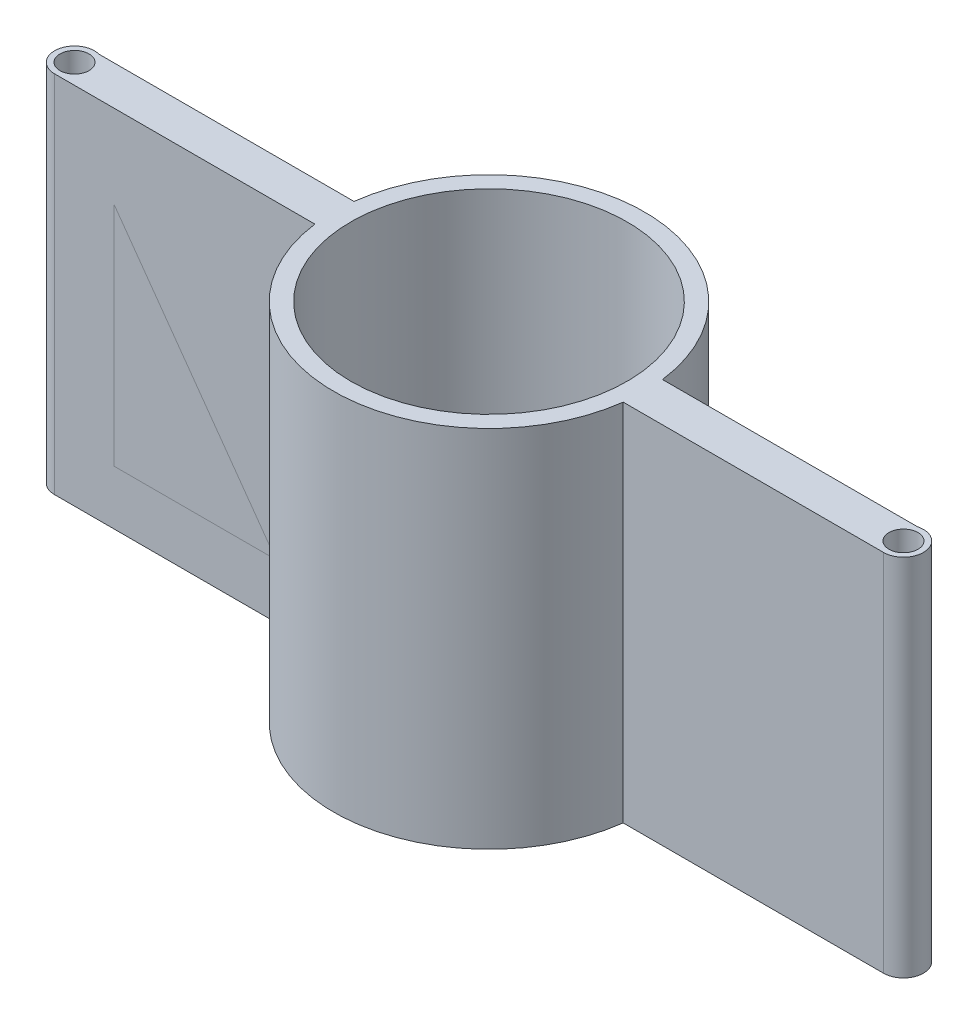
from build123d import *

# Parameters (mm, degrees)
SKETCH1_R           = 25.4
SKETCH1_R_2         = 2.669147435
BOSS_EXTRUDE1_DEPTH = 67
SKETCH4_W           = 36.879658646
SKETCH4_H           = 47
BOSS_EXTRUDE2_DEPTH = 7.209
SKETCH5_W           = 36.879658646
SKETCH5_H           = 47
BOSS_EXTRUDE3_DEPTH = 7.209


with BuildPart() as part:
    # Sketch1 → Boss-Extrude1 (new body)
    with BuildSketch(Plane(origin=(0, 0, 0), x_dir=(1, 0, 0), z_dir=(0, 1, 0))):
        with BuildLine():
            ThreePointArc((76.2, -3.669147435), (79.83668007, 0.487032823), (75.234553617, 3.539852565))
            Line((75.234553617, 3.539852565), (28.354894971, 3.539852565))
            ThreePointArc((28.354894971, 3.539852565), (0, 28.575), (-28.354894971, 3.539852565))
            Line((-28.354894971, 3.539852565), (-75.234553617, 3.539852565))
            ThreePointArc((-75.234553617, 3.539852565), (-79.83668007, 0.487032823), (-76.2, -3.669147435))
            Line((-76.2, -3.669147435), (-28.338454123, -3.669147435))
            ThreePointArc((-28.338454123, -3.669147435), (0, -28.575), (28.338454123, -3.669147435))
            Line((28.338454123, -3.669147435), (76.2, -3.669147435))
        make_face()
        Circle(SKETCH1_R, mode=Mode.SUBTRACT)
        with Locations((-76.2, 0)):
            Circle(SKETCH1_R_2, mode=Mode.SUBTRACT)
        with Locations((76.2, 0)):
            Circle(SKETCH1_R_2, mode=Mode.SUBTRACT)
    extrude(amount=BOSS_EXTRUDE1_DEPTH)


with BuildPart() as body_2:
    # Sketch4 → Boss-Extrude2 (new body)
    with BuildSketch(Plane(origin=(0, 0, -3.539852565), x_dir=(-1, 0, 0), z_dir=(0, 0, -1))):
        with Locations((46.794724294, 33.5)):
            Rectangle(SKETCH4_W, SKETCH4_H)
    extrude(amount=-BOSS_EXTRUDE2_DEPTH)


with BuildPart() as body_3:
    # Sketch5 → Boss-Extrude3 (new body)
    with BuildSketch(Plane(origin=(0, 0, -3.539852565), x_dir=(-1, 0, 0), z_dir=(0, 0, -1))):
        with Locations((-46.794724294, 33.5)):
            Rectangle(SKETCH5_W, SKETCH5_H)
    extrude(amount=-BOSS_EXTRUDE3_DEPTH)


solid = Compound([part.part, body_2.part, body_3.part])
